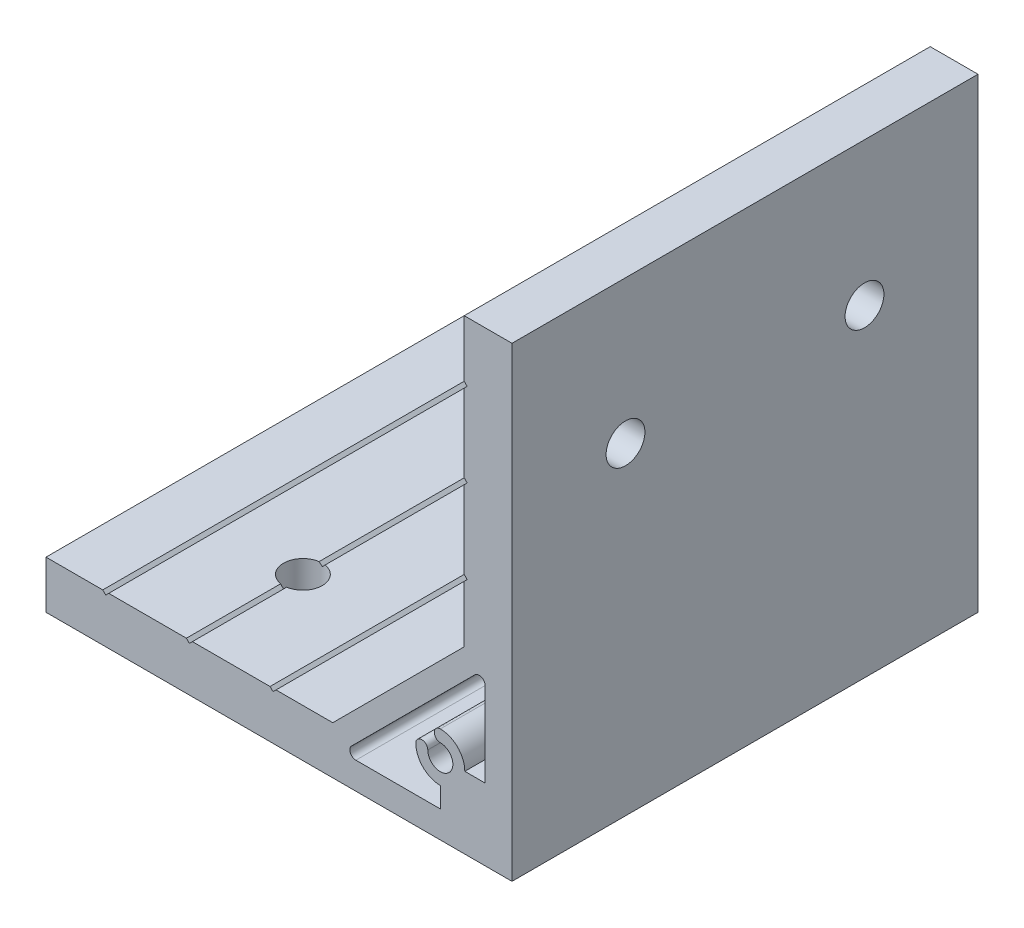
from build123d import *

# Parameters (mm, degrees)
EXTRUDE_1_DEPTH     = 39
SKETCH_2_R          = 3.25
CUT_EXTRUDE_1_DEPTH = 9
SKETCH_3_R          = 3.25
CUT_EXTRUDE_2_DEPTH = 9


with BuildPart() as part:
    # Эскиз1 → Бобышка-Вытянуть1 (new body, symmetric)
    with BuildSketch(Plane.XY):
        Polygon((-78, 0), (0, 0), (0, 78), (-8, 78), (-8, 68.5), (-7.5, 68), (-8, 67.5), (-8, 54.5), (-7.5, 54), (-8, 53.5), (-8, 40.5), (-7.5, 40), (-8, 39.5), (-8, 30), (-30, 8), (-39.5, 8), (-40, 7.5), (-40.5, 8), (-53.5, 8), (-54, 7.5), (-54.5, 8), (-67.5, 8), (-68, 7.5), (-68.5, 8), (-78, 8), align=None)
        with BuildLine():
            Line((-4.5, 12), (-4.5, 26.136038969))
            ThreePointArc((-4.5, 26.136038969), (-5.117316568, 27.059918502), (-6.207106781, 26.843145751))
            Line((-6.207106781, 26.843145751), (-26.843145751, 6.207106781))
            ThreePointArc((-26.843145751, 6.207106781), (-27.059918502, 5.117316568), (-26.136038969, 4.5))
            Line((-26.136038969, 4.5), (-12, 4.5))
            Line((-12, 4.5), (-12, 7.9))
            ThreePointArc((-12, 7.9), (-14.899137803, 9.100862197), (-16.1, 12))
            ThreePointArc((-16.1, 12), (-15.1, 13), (-14.1, 12))
            ThreePointArc((-14.1, 12), (-10.51507576, 10.51507576), (-12, 14.1))
            ThreePointArc((-12, 14.1), (-13, 15.1), (-12, 16.1))
            ThreePointArc((-12, 16.1), (-9.100862197, 14.899137803), (-7.9, 12))
            Line((-7.9, 12), (-4.5, 12))
        make_face(mode=Mode.SUBTRACT)
    extrude(amount=EXTRUDE_1_DEPTH, both=True)

    # Эскиз2 → Вырез-Вытянуть1 (cut, through all)
    with BuildSketch(Plane.ZY.offset(8)):
        with Locations(Location((-20, 54, 0), (0, 0, 270))):  # turned: the seam where the file's is
            Circle(SKETCH_2_R)
        with Locations(Location((20, 54, 0), (0, 0, 270))):  # turned: the seam where the file's is
            Circle(SKETCH_2_R)
    extrude(amount=-CUT_EXTRUDE_1_DEPTH, mode=Mode.SUBTRACT)

    # Эскиз3 → Вырез-Вытянуть2 (cut, through all)
    with BuildSketch(Plane(origin=(0, 8, 0), x_dir=(1, 0, 0), z_dir=(0, 1, 0))):
        with Locations(Location((-54, -20, 0), (0, 0, 180))):  # turned: the seam where the file's is
            Circle(SKETCH_3_R)
        with Locations(Location((-54, 20, 0), (0, 0, 180))):  # turned: the seam where the file's is
            Circle(SKETCH_3_R)
    extrude(amount=-CUT_EXTRUDE_2_DEPTH, mode=Mode.SUBTRACT)


solid = part.part
